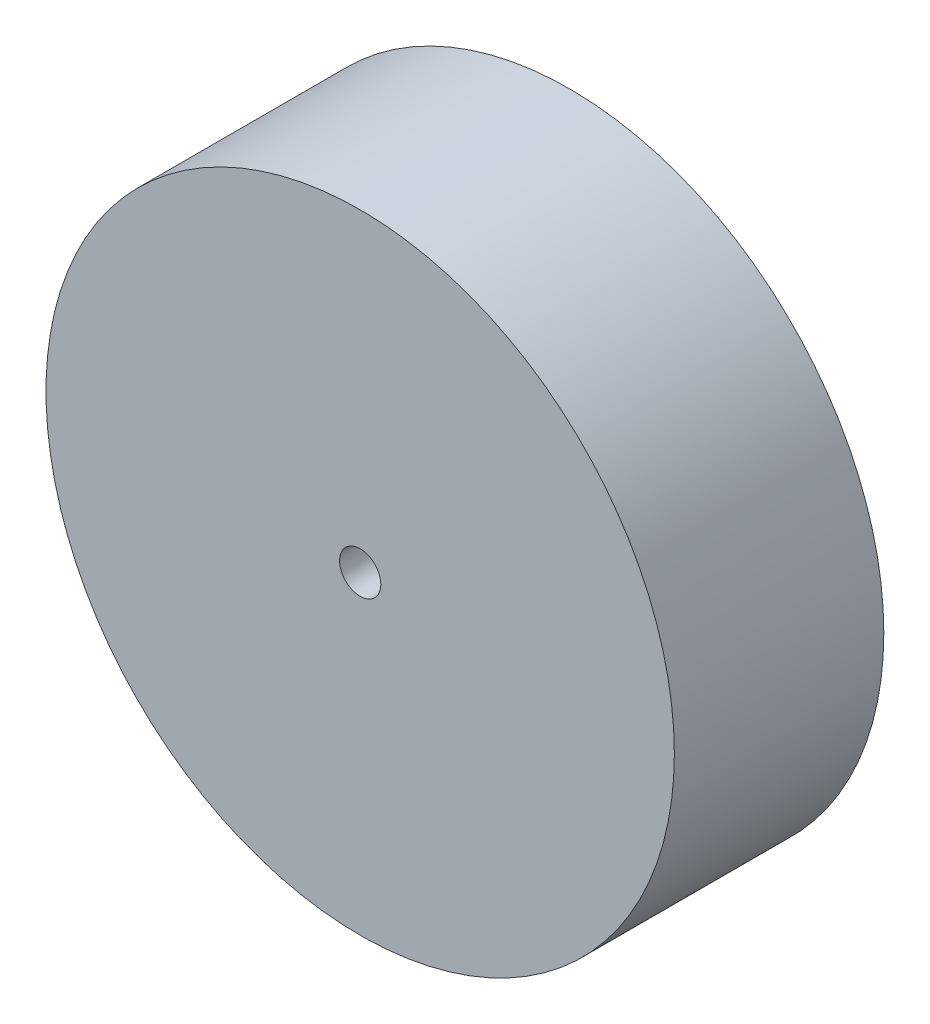
from build123d import *

# Parameters (mm, degrees)
SKETCH1_R      = 38.1
EXTRUDE1_DEPTH = 25.4
SKETCH2_R      = 2.5
EXTRUDE2_DEPTH = 15


with BuildPart() as part:
    # Sketch1 → Extrude1 (new body)
    with BuildSketch(Plane.XY):
        Circle(SKETCH1_R)
    extrude(amount=EXTRUDE1_DEPTH)

    # Sketch2 → Extrude2 (cut)
    with BuildSketch(Plane.XY.offset(25.4)):
        Circle(SKETCH2_R)
    extrude(amount=-EXTRUDE2_DEPTH, mode=Mode.SUBTRACT)


solid = part.part
